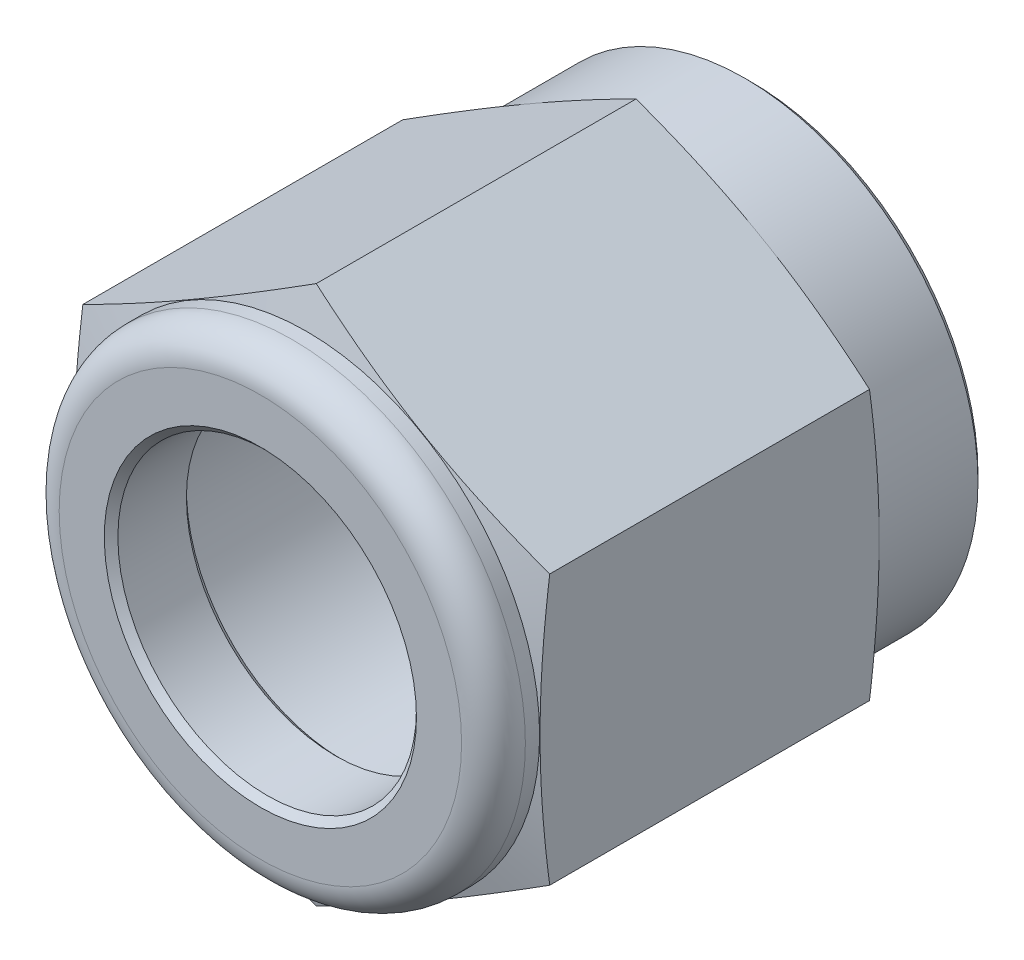
from build123d import *

# Parameters (mm, degrees)
BOSS_EXTRUDE1_DEPTH = 18.3896
FILLET1_R           = 1.1938
CHAMFER1_SIZE       = 0.254
CHAMFER2_SIZE       = 0.254


with BuildPart() as part:
    # Sketch1 → Boss-Extrude1 (new body)
    with BuildSketch(Plane.XY):
        Polygon((0, 10.089311424), (-8.7376, 5.044655712), (-8.7376, -5.044655712), (0, -10.089311424), (8.7376, -5.044655712), (8.7376, 5.044655712), align=None)
    extrude(amount=BOSS_EXTRUDE1_DEPTH)

    # Sketch2 → Cut-Revolve1 (revolve, cut)
    with BuildSketch(Plane(origin=(0, 0, 0), x_dir=(0, 0, -1), z_dir=(1, 0, 0))):
        Polygon((-18.3896, 11.453722848), (-18.3896, 8.7249), (-16.6624, 8.7249), (-16.296807061, 10.089311424), (-4.327992939, 10.089311424), (-3.9624, 8.7249), (0, 8.7249), (0, 11.453722848), align=None)
        with BuildLine():
            Line((-18.3896, 5.588), (-18.3896, 0))
            Line((-18.3896, 0), (0, 0))
            Line((0, 0), (0, 6.370416378))
            Line((0, 6.370416378), (-15.0622, 6.370416378))
            ThreePointArc((-15.0622, 6.370416378), (-15.241805122, 6.2960215), (-15.3162, 6.116416378))
            Line((-15.3162, 6.116416378), (-15.3162, 5.588))
            Line((-15.3162, 5.588), (-18.3896, 5.588))
        make_face()
    revolve(axis=Axis((0, 0, 0), (0, 0, 1)), mode=Mode.SUBTRACT)

    # Fillet1
    fillet1_edges = [part.edges().sort_by_distance(p)[0] for p in [
        (0, -8.7249, 18.3896),
    ]]
    fillet(fillet1_edges, radius=FILLET1_R)

    # Chamfer1
    chamfer1_edges = [part.edges().sort_by_distance(p)[0] for p in [
        (0, -8.7249, 0),
    ]]
    chamfer(chamfer1_edges, length=CHAMFER1_SIZE)

    # Chamfer2
    chamfer2_edges = [part.edges().sort_by_distance(p)[0] for p in [
        (0, -5.588, 18.3896),
        (0, -5.588, 15.3162),
    ]]
    chamfer(chamfer2_edges, length=CHAMFER2_SIZE)


solid = part.part
